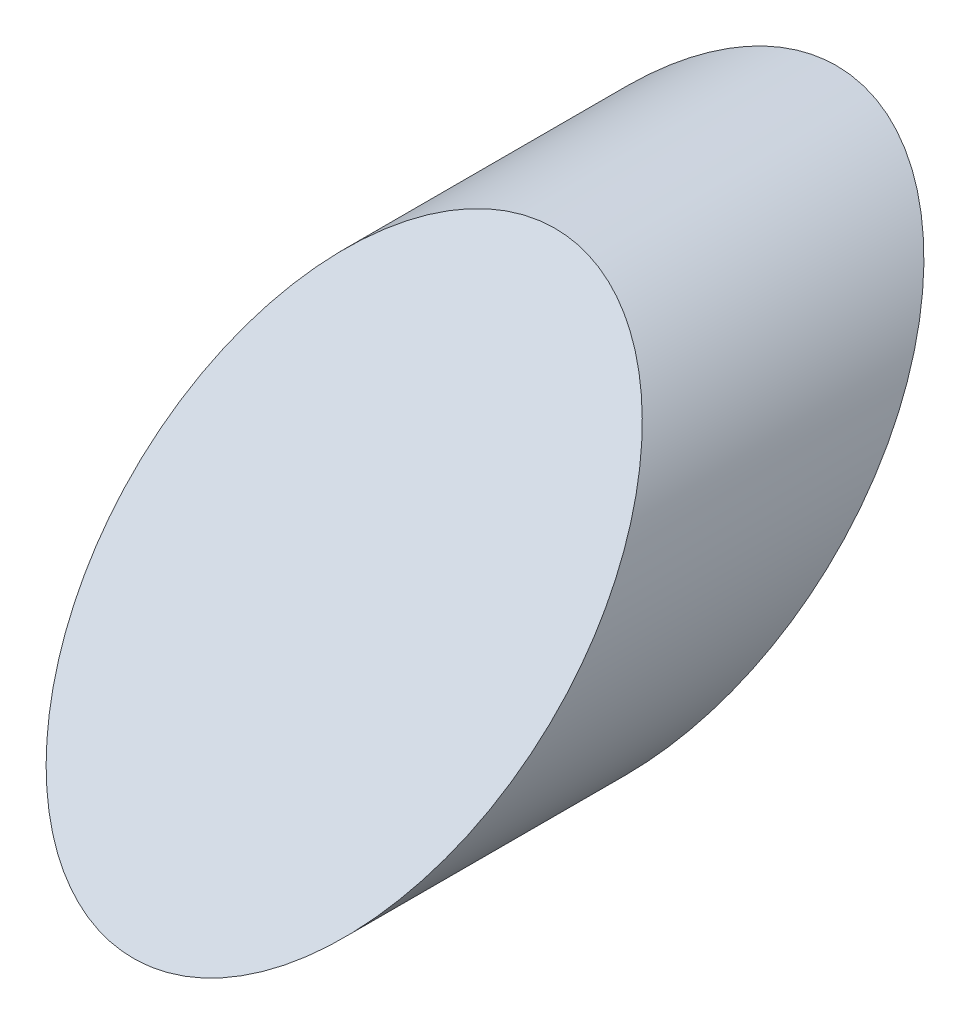
from build123d import *

# Parameters (mm, degrees)
SKETCH1_R               = 6.35
BOSS_EXTRUDE1_DEPTH     = 25.4
SKETCH3_OUTSIDE_W       = 33.622
SKETCH3_OUTSIDE_H       = 20.922
CUT_EXTRUDE1_DEPTH      = 7.35
CUT_EXTRUDE1_DEPTH_BACK = 7.35


with BuildPart() as part:
    # Sketch1 → Boss-Extrude1 (new body)
    with BuildSketch(Plane.XY):
        Circle(SKETCH1_R)
    extrude(amount=BOSS_EXTRUDE1_DEPTH)

    # Sketch3 outside → Cut-Extrude1 (cut, two sides)
    with BuildSketch(Plane(origin=(0, 0, 0), x_dir=(0, 0, -1), z_dir=(1, 0, 0))) as cut_extrude1_sk:
        with Locations((-12.7, 0)):
            Rectangle(SKETCH3_OUTSIDE_W, SKETCH3_OUTSIDE_H)
        Polygon((-25.617510327, -10.782228953), (-2.912903275, 11.922378099), (5.572378099, 11.922378099), (-17.132228953, -10.782228953), align=None, mode=Mode.SUBTRACT)
    extrude(amount=CUT_EXTRUDE1_DEPTH, mode=Mode.SUBTRACT)
    extrude(cut_extrude1_sk.sketch, amount=-CUT_EXTRUDE1_DEPTH_BACK, mode=Mode.SUBTRACT)


solid = part.part
